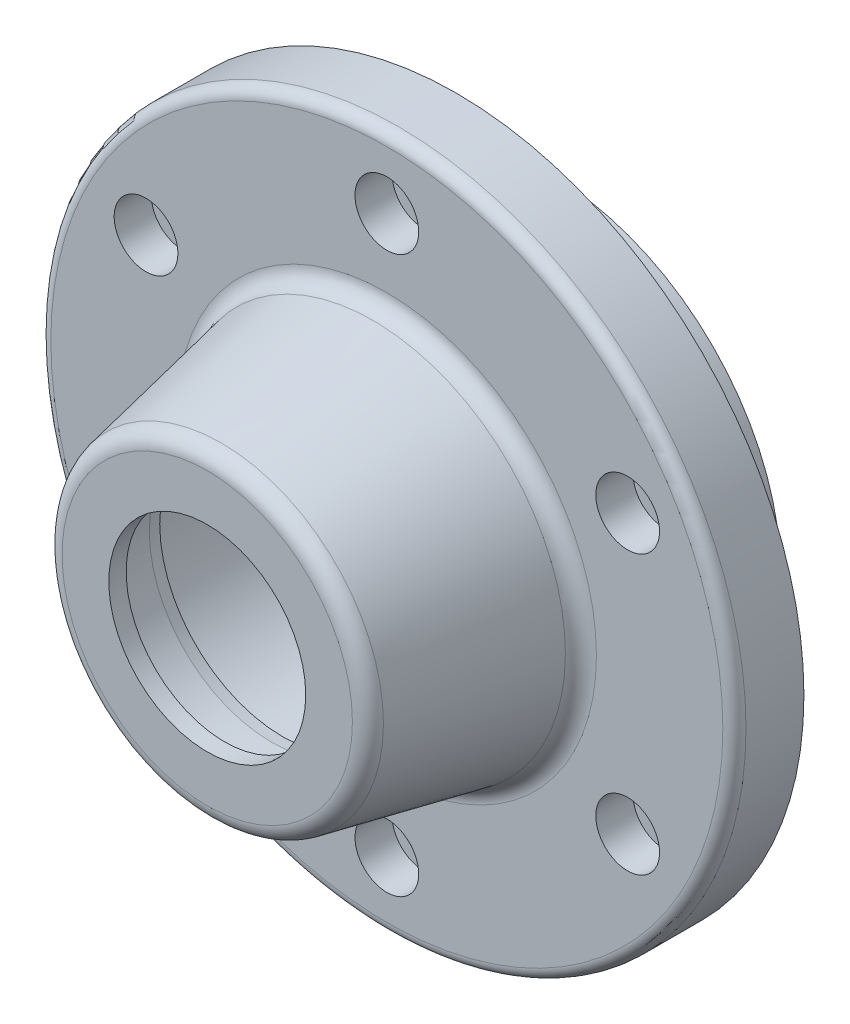
from build123d import *

# Parameters (mm, degrees)
HOLE1_D           = 7
HOLE1_DEPTH       = 12
HOLE1_CBORE_D     = 11
HOLE1_CBORE_DEPTH = 6.4
CIRPATTERN1_COUNT = 6


with BuildPart() as part:
    # Sketch1 → Revolve1 (revolve)
    with BuildSketch(Plane(origin=(0, 0, 0), x_dir=(0, 0, -1), z_dir=(1, 0, 0))):
        with BuildLine():
            Line((-63, -17), (-63, -25.058257973))
            ThreePointArc((-63, -25.058257973), (-62.320026424, -26.96022469), (-60.588348405, -28))
            Line((-60.588348405, -28), (-34.411651595, -33.235339362))
            ThreePointArc((-34.411651595, -33.235339362), (-32.679973576, -34.275114672), (-32, -36.177081389))
            Line((-32, -36.177081389), (-32, -58))
            ThreePointArc((-32, -58), (-31.414213562, -59.414213562), (-30, -60))
            Line((-30, -60), (-20, -60))
            Line((-20, -60), (-20, -40))
            Line((-20, -40), (-4, -40))
            Line((-4, -40), (-4, -31))
            Line((-4, -31), (0, -31))
            Line((0, -31), (0, -23.75))
            Line((0, -23.75), (-3.5, -23.75))
            Line((-3.5, -23.75), (-3.5, -24.75))
            Line((-3.5, -24.75), (-5.35, -24.75))
            Line((-5.35, -24.75), (-5.35, -23.5))
            Line((-5.35, -23.5), (-21.5, -23.5))
            ThreePointArc((-21.5, -23.5), (-22.085786438, -24.914213562), (-23.5, -25.5))
            Line((-23.5, -25.5), (-32, -25.5))
            ThreePointArc((-32, -25.5), (-33.414213562, -24.914213562), (-34, -23.5))
            Line((-34, -23.5), (-50, -23.5))
            Line((-50, -23.5), (-50, -21.210208471))
            Line((-50, -21.210208471), (-52, -21))
            Line((-52, -21), (-60, -21))
            Line((-60, -21), (-60, -17))
            Line((-60, -17), (-63, -17))
        make_face()
    revolve(axis=Axis((0, 0, 82.747560133), (0, 0, -1)))

    # Hole1
    with Locations(Plane.XY.offset(32)):
        with Locations((0, 48)):
            hole1 = CounterBoreHole(HOLE1_D / 2, HOLE1_CBORE_D / 2, HOLE1_CBORE_DEPTH, depth=HOLE1_DEPTH)

    # CirPattern1: Hole1 ×6 about axis
    cirpattern1_axis = Axis((0, 0, 0), (0, 0, 1))
    for i in range(1, CIRPATTERN1_COUNT):
        add(hole1.rotate(cirpattern1_axis, i * 360 / CIRPATTERN1_COUNT), mode=Mode.SUBTRACT)


solid = part.part
